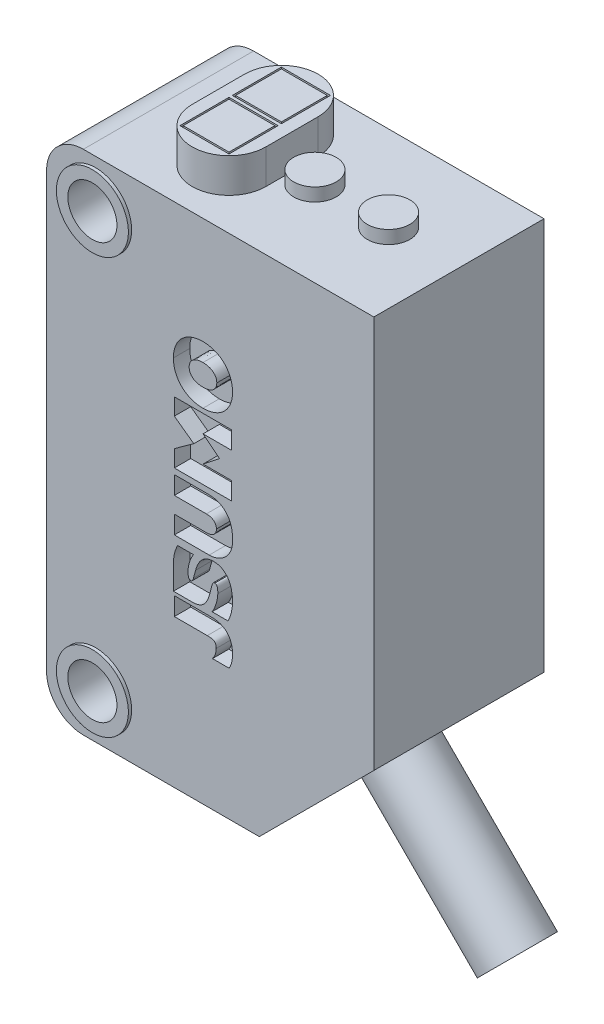
from build123d import *

# Parameters (mm, degrees)
SALIENTE_EXTRUIR1_DEPTH           = 10.4
SALIENTE_EXTRUIR2_DEPTH           = 2.1
CROQUIS3_W                        = 3
CROQUIS3_H                        = 3
CORTAR_EXTRUIR1_DEPTH             = 1
CROQUIS4_W                        = 2.8
CROQUIS4_H                        = 2.8
SALIENTE_EXTRUIR3_DEPTH           = 1
CROQUIS5_W                        = 3
CROQUIS5_H                        = 3
CORTAR_EXTRUIR2_DEPTH             = 1
CROQUIS6_W                        = 2.8
CROQUIS6_H                        = 2.8
SALIENTE_EXTRUIR4_DEPTH           = 1
CORTAR_EXTRUIR3_START             = 3
CORTAR_EXTRUIR3_DEPTH             = 1
SALIENTE_EXTRUIR5_START           = 2.999999
SALIENTE_EXTRUIR5_DEPTH           = 1
CROQUIS9_W                        = 7.2
CROQUIS9_H                        = 15.4
CORTAR_EXTRUIR4_DEPTH             = 1
CROQUIS10_W                       = 7
CROQUIS10_H                       = 15.2
SALIENTE_EXTRUIR6_DEPTH           = 1
CORTAR_EXTRUIR5_START             = 3
CORTAR_EXTRUIR5_DEPTH             = 1
CORTAR_EXTRUIR6_DEPTH             = 1
CORTAR_EXTRUIR7_START             = 3
CORTAR_EXTRUIR7_DEPTH             = 1
CORTAR_EXTRUIR8_START             = 3
CORTAR_EXTRUIR8_DEPTH             = 1
CROQUIS15_W                       = 2.2
CROQUIS15_H                       = 0.2
CROQUIS16_W                       = 2.2
CROQUIS16_H                       = 0.2
CROQUIS17_W                       = 1.3
CROQUIS17_H                       = 0.8
CROQUIS18_W                       = 1.3
CROQUIS18_H                       = 0.8
CROQUIS20_W                       = 2.2
CROQUIS20_H                       = 0.2
CROQUIS21_W                       = 2.2
CROQUIS21_H                       = 0.2
DI_METRO_DE_TALADRO_3_0_3_1_D     = 3
DI_METRO_DE_TALADRO_3_0_3_1_DEPTH = 10.8
CHAFL_N1_SIZE2                    = 0.018573
CHAFL_N1_SIZE                     = 0.018603
REDONDEO4_R                       = 1.427409
REDONDEO5_R                       = 2.25


with BuildPart() as part:
    # Croquis1 → Saliente-Extruir1 (new body)
    with BuildSketch(Plane.XY.offset(5.2)):
        Polygon((17, 28.2), (-3, 28.2), (-3, -2.8), (10, -2.8), (17, 4.2), align=None)
    extrude(amount=-SALIENTE_EXTRUIR1_DEPTH)

    # Croquis2 → Saliente-Extruir2 (add)
    with BuildSketch(Plane(origin=(0, 28.2, 0), x_dir=(-1, 0, 0), z_dir=(0, 1, 0))):
        with BuildLine():
            Line((-6.8, -1.6), (-6.8, 1.6))
            ThreePointArc((-6.8, 1.6), (-4.55, 3.85), (-2.3, 1.6))
            Line((-2.3, 1.6), (-2.3, -1.6))
            ThreePointArc((-2.3, -1.6), (-4.55, -3.85), (-6.8, -1.6))
        make_face()
    extrude(amount=SALIENTE_EXTRUIR2_DEPTH)

    # Croquis3 → Cortar-Extruir1 (cut)
    with BuildSketch(Plane(origin=(0, 30.3, 0), x_dir=(-1, 0, 0), z_dir=(0, 1, 0))):
        with Locations((-4.55, 1.6)):
            Rectangle(CROQUIS3_W, CROQUIS3_H)
    extrude(amount=-CORTAR_EXTRUIR1_DEPTH, mode=Mode.SUBTRACT)

    # Croquis4 → Saliente-Extruir3 (add)
    with BuildSketch(Plane(origin=(0, 29.3, 0), x_dir=(-1, 0, 0), z_dir=(0, 1, 0))):
        with Locations((-4.55, 1.6)):
            Rectangle(CROQUIS4_W, CROQUIS4_H)
    extrude(amount=SALIENTE_EXTRUIR3_DEPTH)

    # Croquis5 → Cortar-Extruir2 (cut)
    with BuildSketch(Plane(origin=(0, 30.3, 0), x_dir=(-1, 0, 0), z_dir=(0, 1, 0))):
        with Locations((-4.55, -1.6)):
            Rectangle(CROQUIS5_W, CROQUIS5_H)
    extrude(amount=-CORTAR_EXTRUIR2_DEPTH, mode=Mode.SUBTRACT)

    # Croquis6 → Saliente-Extruir4 (add)
    with BuildSketch(Plane(origin=(0, 29.3, 0), x_dir=(-1, 0, 0), z_dir=(0, 1, 0))):
        with Locations((-4.55, -1.6)):
            Rectangle(CROQUIS6_W, CROQUIS6_H)
    extrude(amount=SALIENTE_EXTRUIR4_DEPTH)

    # Croquis7 → Cortar-Extruir3 (cut)
    with BuildSketch(Plane.XY.offset(2.2).offset(CORTAR_EXTRUIR3_START)):
        with BuildLine():
            add(Edge.make_bspline(
                [(6.556872, 18.148819), (6.483725, 18.150816), (6.337677, 18.154804), (6.121183, 18.188602), (5.910126, 18.244942), (5.707723, 18.327105), (5.516427, 18.432012), (5.340199, 18.560774), (5.182694, 18.711531), (5.047783, 18.882324), (4.937629, 19.069758), (4.851912, 19.269257), (4.792935, 19.478347), (4.758251, 19.693079), (4.754314, 19.837794), (4.75234, 19.910386)],
                knots=[0, 0, 0, 0, 0.077583, 0.154906, 0.231879, 0.30891, 0.386121, 0.462825, 0.539834, 0.616769, 0.693013, 0.769892, 0.846517, 0.923009, 1, 1, 1, 1], degree=3))
            add(Edge.make_bspline(
                [(4.75234, 19.910386), (4.755244, 19.996969), (4.761039, 20.169708), (4.810891, 20.424588), (4.896052, 20.669184), (5.016774, 20.897814), (5.171979, 21.104833), (5.358358, 21.283013), (5.57019, 21.430011), (5.801571, 21.543646), (6.046304, 21.623739), (6.300022, 21.670701), (6.471081, 21.675937), (6.556872, 21.678564)],
                knots=[0, 0, 0, 0, 0.091665, 0.182879, 0.273878, 0.36517, 0.455665, 0.546797, 0.637127, 0.72777, 0.8189, 0.909173, 1, 1, 1, 1], degree=3))
            add(Edge.make_bspline(
                [(6.556872, 21.678564), (6.630149, 21.676559), (6.776466, 21.672556), (6.993384, 21.638707), (7.204923, 21.582404), (7.40789, 21.500435), (7.599335, 21.395146), (7.775018, 21.265316), (7.930975, 21.1125), (8.065046, 20.940354), (8.175389, 20.75225), (8.262615, 20.552773), (8.322906, 20.343496), (8.35857, 20.128313), (8.362659, 19.983181), (8.36471, 19.910386)],
                knots=[0, 0, 0, 0, 0.077553, 0.154856, 0.23183, 0.308876, 0.386038, 0.462576, 0.539436, 0.616515, 0.692911, 0.769779, 0.846411, 0.922962, 1, 1, 1, 1], degree=3))
            add(Edge.make_bspline(
                [(8.36471, 19.910386), (8.36257, 19.837209), (8.358298, 19.691134), (8.322, 19.47499), (8.261259, 19.265189), (8.172668, 19.065609), (8.061324, 18.878222), (7.926162, 18.707184), (7.769055, 18.556054), (7.592739, 18.427714), (7.400911, 18.323567), (7.198592, 18.243), (6.988502, 18.1873), (6.773795, 18.154423), (6.62935, 18.150691), (6.556872, 18.148819)],
                knots=[0, 0, 0, 0, 0.077586, 0.154877, 0.231765, 0.308711, 0.38586, 0.462416, 0.539246, 0.616397, 0.693033, 0.77021, 0.846843, 0.92315, 1, 1, 1, 1], degree=3))
        make_face()
    extrude(amount=-CORTAR_EXTRUIR3_DEPTH, mode=Mode.SUBTRACT)

    # Croquis8 → Saliente-Extruir5 (add)
    with BuildSketch(Plane.YX.offset(-7.199999).offset(SALIENTE_EXTRUIR5_START)):
        with BuildLine():
            add(Edge.make_bspline(
                [(19.910386, 7.402953), (19.955401, 7.400482), (20.045168, 7.395552), (20.174236, 7.352347), (20.288533, 7.280318), (20.383659, 7.184737), (20.458699, 7.073121), (20.512232, 6.950162), (20.546386, 6.821354), (20.565151, 6.689688), (20.567102, 6.601264), (20.568082, 6.556872)],
                knots=[0, 0, 0, 0, 0.112118, 0.223579, 0.335249, 0.446416, 0.557621, 0.668998, 0.779436, 0.889269, 1, 1, 1, 1], degree=3))
            add(Edge.make_bspline(
                [(20.568082, 6.556872), (20.567108, 6.512451), (20.565165, 6.42381), (20.546234, 6.291805), (20.511925, 6.162817), (20.457847, 6.039851), (20.382001, 5.92867), (20.286302, 5.834214), (20.172344, 5.763528), (20.044249, 5.721475), (19.955146, 5.716563), (19.910386, 5.714096)],
                knots=[0, 0, 0, 0, 0.111022, 0.221544, 0.332555, 0.443846, 0.555736, 0.667127, 0.777586, 0.888274, 1, 1, 1, 1], degree=3))
            add(Edge.make_bspline(
                [(19.910386, 5.714096), (19.865782, 5.716498), (19.776895, 5.721285), (19.649022, 5.763678), (19.535856, 5.835057), (19.442112, 5.930472), (19.368765, 6.041985), (19.316647, 6.164709), (19.283618, 6.293206), (19.265415, 6.424535), (19.263543, 6.512687), (19.262605, 6.556872)],
                knots=[0, 0, 0, 0, 0.111874, 0.222944, 0.334151, 0.445119, 0.556478, 0.667657, 0.778571, 0.889013, 1, 1, 1, 1], degree=3))
            add(Edge.make_bspline(
                [(19.262605, 6.556872), (19.263548, 6.60115), (19.265429, 6.689488), (19.283687, 6.821098), (19.31677, 6.949936), (19.36898, 7.073198), (19.442548, 7.18545), (19.536363, 7.281307), (19.649272, 7.353128), (19.776902, 7.395546), (19.865747, 7.400476), (19.910386, 7.402953)],
                knots=[0, 0, 0, 0, 0.111002, 0.221461, 0.332406, 0.443751, 0.555604, 0.667102, 0.777567, 0.88824, 1, 1, 1, 1], degree=3))
        make_face()
    extrude(amount=-SALIENTE_EXTRUIR5_DEPTH)

    # Croquis9 → Cortar-Extruir4 (cut)
    with BuildSketch(Plane.ZY.offset(3)):
        with Locations((0, 12.7)):
            Rectangle(CROQUIS9_W, CROQUIS9_H)
    extrude(amount=-CORTAR_EXTRUIR4_DEPTH, mode=Mode.SUBTRACT)

    # Croquis10 → Saliente-Extruir6 (add)
    with BuildSketch(Plane.ZY.offset(2)):
        with Locations((0, 12.7)):
            Rectangle(CROQUIS10_W, CROQUIS10_H)
    extrude(amount=SALIENTE_EXTRUIR6_DEPTH)

    # Croquis11 → Cortar-Extruir5 (cut)
    with BuildSketch(Plane.XY.offset(2.2).offset(CORTAR_EXTRUIR5_START)):
        with BuildLine():
            Line((7.112113, 9.066666), (6.973303, 8.531255))
            add(Edge.make_bspline(
                [(6.973303, 8.531255), (6.955912, 8.468461), (6.921217, 8.343179), (6.849591, 8.161506), (6.758362, 7.988744), (6.639771, 7.832516), (6.489756, 7.705008), (6.31243, 7.620371), (6.122535, 7.573299), (5.927389, 7.561443), (5.732121, 7.563278), (5.536184, 7.562784), (5.340227, 7.562917), (5.144263, 7.562881), (4.948302, 7.56289), (4.81766, 7.562889), (4.75234, 7.562889)],
                knots=[0, 0, 0, 0, 0.071468, 0.142587, 0.213863, 0.285264, 0.356574, 0.427679, 0.498905, 0.569946, 0.641582, 0.713266, 0.784949, 0.856633, 0.928316, 1, 1, 1, 1], degree=3))
            add(Edge.make_bspline(
                [(4.75234, 7.562889), (4.75234, 7.641286), (4.752341, 7.798081), (4.752335, 8.033273), (4.752357, 8.268465), (4.752274, 8.503656), (4.752583, 8.738847), (4.751432, 8.973949), (4.756671, 9.208977), (4.780691, 9.443058), (4.832941, 9.672404), (4.905302, 9.89614), (4.968578, 10.039413), (5.000215, 10.111047)],
                knots=[0, 0, 0, 0, 0.090975, 0.18195, 0.272925, 0.363901, 0.454876, 0.545848, 0.636727, 0.727592, 0.818347, 0.909177, 1, 1, 1, 1], degree=3))
            Line((5.000215, 10.111047), (5.981801, 10.111047))
            add(Edge.make_bspline(
                [(5.981801, 10.111047), (5.941398, 10.04575), (5.8607, 9.915332), (5.766082, 9.704853), (5.695092, 9.485476), (5.652387, 9.25786), (5.647258, 9.104001), (5.644691, 9.027006)],
                knots=[0, 0, 0, 0, 0.199872, 0.399203, 0.599389, 0.799522, 1, 1, 1, 1], degree=3))
            add(Edge.make_bspline(
                [(5.644691, 9.027006), (5.644922, 9.006078), (5.645382, 8.964288), (5.650072, 8.901753), (5.659105, 8.839635), (5.673072, 8.778216), (5.693918, 8.71901), (5.736722, 8.66771), (5.778939, 8.660464), (5.800026, 8.656845)],
                knots=[0, 0, 0, 0, 0.1431, 0.285746, 0.42843, 0.572117, 0.715442, 0.857868, 1, 1, 1, 1], degree=3))
            add(Edge.make_bspline(
                [(5.800026, 8.656845), (5.806361, 8.656986), (5.81904, 8.657267), (5.837897, 8.65988), (5.85637, 8.664565), (5.873994, 8.671884), (5.89023, 8.681989), (5.904379, 8.694883), (5.915865, 8.710179), (5.925724, 8.726548), (5.934547, 8.743537), (5.942418, 8.760978), (5.949553, 8.77872), (5.955996, 8.796723), (5.961822, 8.814943), (5.967137, 8.833318), (5.970304, 8.845668), (5.971886, 8.85184)],
                knots=[0, 0, 0, 0, 0.066408, 0.132903, 0.199147, 0.26576, 0.332201, 0.398718, 0.465217, 0.532037, 0.598964, 0.665842, 0.732619, 0.799443, 0.86631, 0.933183, 1, 1, 1, 1], degree=3))
            Line((5.971886, 8.85184), (6.107391, 9.350896))
            add(Edge.make_bspline(
                [(6.107391, 9.350896), (6.124781, 9.408738), (6.159482, 9.524165), (6.22699, 9.692179), (6.309121, 9.853763), (6.410653, 10.004641), (6.535163, 10.137524), (6.682919, 10.244074), (6.848726, 10.318819), (7.026188, 10.361732), (7.147252, 10.366465), (7.207958, 10.368838)],
                knots=[0, 0, 0, 0, 0.111151, 0.221808, 0.332849, 0.444308, 0.55549, 0.666318, 0.777362, 0.888361, 1, 1, 1, 1], degree=3))
            add(Edge.make_bspline(
                [(7.207958, 10.368838), (7.274288, 10.366206), (7.406355, 10.360965), (7.599778, 10.313101), (7.777624, 10.225287), (7.934842, 10.104911), (8.066753, 9.956784), (8.170503, 9.787886), (8.248583, 9.605628), (8.303439, 9.415687), (8.339029, 9.221838), (8.360916, 9.025914), (8.363443, 8.894548), (8.36471, 8.828705)],
                knots=[0, 0, 0, 0, 0.091618, 0.182415, 0.273062, 0.363956, 0.454492, 0.545705, 0.636789, 0.727809, 0.818436, 0.908997, 1, 1, 1, 1], degree=3))
            ThreePointArc((8.36471, 8.828705), (8.297363, 8.227351), (8.090394, 7.658734))
            Line((8.090394, 7.658734), (7.115418, 7.658734))
            add(Edge.make_bspline(
                [(7.115418, 7.658734), (7.155834, 7.727806), (7.236564, 7.865778), (7.326556, 8.08885), (7.39839, 8.317637), (7.453603, 8.552301), (7.461702, 8.712368), (7.465748, 8.79235)],
                knots=[0, 0, 0, 0, 0.199963, 0.399423, 0.599832, 0.800046, 1, 1, 1, 1], degree=3))
            add(Edge.make_bspline(
                [(7.465748, 8.79235), (7.465653, 8.812737), (7.465463, 8.853483), (7.463241, 8.914528), (7.458786, 8.975387), (7.451175, 9.035991), (7.440338, 9.096173), (7.423174, 9.155299), (7.392435, 9.208755), (7.342807, 9.249605), (7.30142, 9.253232), (7.280668, 9.255051)],
                knots=[0, 0, 0, 0, 0.111213, 0.22228, 0.333176, 0.444018, 0.555293, 0.666762, 0.777925, 0.888647, 1, 1, 1, 1], degree=3))
            add(Edge.make_bspline(
                [(7.280668, 9.255051), (7.275526, 9.254964), (7.265242, 9.25479), (7.249883, 9.253213), (7.234728, 9.250399), (7.21992, 9.246034), (7.205756, 9.239846), (7.192571, 9.231721), (7.180945, 9.22148), (7.171141, 9.209483), (7.16309, 9.196249), (7.155584, 9.182686), (7.148759, 9.168744), (7.142447, 9.154573), (7.136555, 9.140229), (7.131047, 9.125735), (7.125881, 9.111109), (7.121027, 9.096375), (7.116428, 9.081561), (7.113551, 9.07163), (7.112113, 9.066666)],
                knots=[0, 0, 0, 0, 0.055408, 0.110811, 0.166162, 0.221319, 0.27682, 0.332262, 0.387543, 0.442988, 0.498534, 0.554262, 0.610031, 0.665753, 0.721428, 0.777124, 0.832843, 0.888576, 0.944304, 1, 1, 1, 1], degree=3))
        make_face()
    extrude(amount=-CORTAR_EXTRUIR5_DEPTH, mode=Mode.SUBTRACT)

    # Croquis12 → Cortar-Extruir6 (cut)
    with BuildSketch(Plane.XY.offset(5.2)):
        Polygon((8.308525, 15.197449), (6.563482, 15.197449), (7.569534, 15.995584), (6.563482, 16.797072), (8.308525, 16.797072), (8.308525, 17.881113), (4.808525, 17.881113), (4.808525, 16.856562), (5.998326, 15.993955), (4.808525, 15.137959), (4.808525, 14.113408), (8.308525, 14.113408), align=None)
    extrude(amount=-CORTAR_EXTRUIR6_DEPTH, mode=Mode.SUBTRACT)

    # Croquis13 → Cortar-Extruir7 (cut)
    with BuildSketch(Plane.XY.offset(2.2).offset(CORTAR_EXTRUIR7_START)):
        with BuildLine():
            Line((4.808525, 10.570443), (4.808525, 11.671009))
            Line((4.808525, 11.671009), (6.765087, 11.671009))
            add(Edge.make_bspline(
                [(6.765087, 11.671009), (6.798075, 11.671722), (6.86394, 11.673144), (6.962096, 11.687251), (7.057913, 11.71315), (7.148724, 11.754261), (7.229683, 11.812429), (7.296983, 11.885709), (7.34624, 11.971953), (7.374902, 12.067539), (7.378175, 12.133586), (7.379818, 12.16676)],
                knots=[0, 0, 0, 0, 0.111168, 0.221966, 0.333409, 0.44482, 0.556141, 0.66724, 0.777653, 0.888318, 1, 1, 1, 1], degree=3))
            add(Edge.make_bspline(
                [(7.379818, 12.16676), (7.378245, 12.200104), (7.375109, 12.266601), (7.346526, 12.363133), (7.296983, 12.450242), (7.22886, 12.523627), (7.147217, 12.581105), (7.05633, 12.621371), (6.960932, 12.64667), (6.863419, 12.660407), (6.797952, 12.661808), (6.765087, 12.662511)],
                knots=[0, 0, 0, 0, 0.11211, 0.223573, 0.335329, 0.446725, 0.557966, 0.669267, 0.779636, 0.889376, 1, 1, 1, 1], degree=3))
            Line((6.765087, 12.662511), (4.808525, 12.662511))
            Line((4.808525, 12.662511), (4.808525, 13.763077))
            Line((4.808525, 13.763077), (6.860933, 13.763077))
            add(Edge.make_bspline(
                [(6.860933, 13.763077), (6.946499, 13.760392), (7.117333, 13.75503), (7.369671, 13.704425), (7.609615, 13.613721), (7.828594, 13.479669), (8.013554, 13.302001), (8.159388, 13.091279), (8.262832, 12.857296), (8.328761, 12.611535), (8.362783, 12.35939), (8.365231, 12.104873), (8.36457, 11.849507), (8.364747, 11.593679), (8.3647, 11.337874), (8.364712, 11.082063), (8.364709, 10.826253), (8.364709, 10.655713), (8.36471, 10.570443)],
                knots=[0, 0, 0, 0, 0.062833, 0.125447, 0.188128, 0.250468, 0.312777, 0.375206, 0.437599, 0.499828, 0.561636, 0.624021, 0.686685, 0.749348, 0.812011, 0.874674, 0.937337, 1, 1, 1, 1], degree=3))
            Line((8.36471, 10.570443), (4.808525, 10.570443))
        make_face()
    extrude(amount=-CORTAR_EXTRUIR7_DEPTH, mode=Mode.SUBTRACT)

    # Croquis14 → Cortar-Extruir8 (cut)
    with BuildSketch(Plane.XY.offset(2.2).offset(CORTAR_EXTRUIR8_START)):
        with BuildLine():
            Line((6.821272, 6.250802), (4.808525, 6.250802))
            Line((4.808525, 6.250802), (4.808525, 7.357978))
            Line((4.808525, 7.357978), (7.065843, 7.357978))
            add(Edge.make_bspline(
                [(7.065843, 7.357978), (7.144479, 7.355834), (7.301391, 7.351555), (7.533638, 7.307448), (7.754343, 7.2241), (7.954559, 7.098474), (8.119905, 6.929049), (8.240554, 6.725641), (8.315854, 6.503084), (8.357883, 6.272586), (8.36243, 6.117203), (8.36471, 6.039281)],
                knots=[0, 0, 0, 0, 0.11179, 0.223069, 0.334514, 0.445622, 0.556592, 0.668011, 0.779099, 0.889223, 1, 1, 1, 1], degree=3))
            add(Edge.make_bspline(
                [(8.36471, 6.039281), (8.364047, 5.996962), (8.362722, 5.912377), (8.351202, 5.786009), (8.33165, 5.660808), (8.302689, 5.537366), (8.264321, 5.416791), (8.21988, 5.297729), (8.175422, 5.225843), (8.153189, 5.189895)],
                knots=[0, 0, 0, 0, 0.143186, 0.28619, 0.428976, 0.571731, 0.714658, 0.85731, 1, 1, 1, 1], degree=3))
            Line((8.153189, 5.189895), (7.138553, 5.189895))
            add(Edge.make_bspline(
                [(7.138553, 5.189895), (7.164815, 5.229057), (7.21723, 5.307219), (7.282512, 5.4323), (7.332911, 5.563982), (7.361592, 5.702768), (7.364926, 5.797018), (7.366598, 5.844286)],
                knots=[0, 0, 0, 0, 0.200574, 0.400315, 0.599104, 0.798946, 1, 1, 1, 1], degree=3))
            add(Edge.make_bspline(
                [(7.366598, 5.844286), (7.366136, 5.868541), (7.365215, 5.916933), (7.354819, 5.98882), (7.334171, 6.058312), (7.299257, 6.122504), (7.244729, 6.171931), (7.178994, 6.203226), (7.109513, 6.224375), (7.03808, 6.237436), (6.966033, 6.245742), (6.893704, 6.250149), (6.845427, 6.250584), (6.821272, 6.250802)],
                knots=[0, 0, 0, 0, 0.091366, 0.182285, 0.272778, 0.363531, 0.453948, 0.544845, 0.635776, 0.727081, 0.818083, 0.908979, 1, 1, 1, 1], degree=3))
        make_face()
    extrude(amount=-CORTAR_EXTRUIR8_DEPTH, mode=Mode.SUBTRACT)

    # Croquis15 → Revolución1 (revolve)
    with BuildSketch(Plane(origin=(0, 25.4, 0), x_dir=(1, 0, 0), z_dir=(0, 1, 0))):
        with Locations((1.1, 5.3)):
            Rectangle(CROQUIS15_W, CROQUIS15_H)
    revolve(axis=Axis((0, 25.4, -5.4), (0, 0, 1)))

    # Croquis16 → Revolución2 (revolve)
    with BuildSketch(Plane(origin=(0, 0, 0), x_dir=(1, 0, 0), z_dir=(0, 1, 0))):
        with Locations((1.1, 5.3)):
            Rectangle(CROQUIS16_W, CROQUIS16_H)
    revolve(axis=Axis((0, 0, -5.4), (0, 0, 1)))

    # Croquis17 → Revolución3 (revolve)
    with BuildSketch(Plane.XY):
        with Locations((8.85, 28.6)):
            Rectangle(CROQUIS17_W, CROQUIS17_H)
    revolve(axis=Axis((8.2, 29, 0), (0, -1, 0)))

    # Croquis18 → Revolución4 (revolve)
    with BuildSketch(Plane.XY):
        with Locations((13.35, 28.6)):
            Rectangle(CROQUIS18_W, CROQUIS18_H)
    revolve(axis=Axis((12.7, 29, 0), (0, -1, 0)))

    # Croquis19 → Revolución5 (revolve)
    with BuildSketch(Plane.XY):
        Polygon((13.5, 0.7), (12.085786, -0.714214), (19.156854, -7.785281), (20.571068, -6.371068), align=None)
    revolve(axis=Axis((20.571068, -6.371068, 0), (-0.707107, 0.707107, 0)))

    # Croquis20 → Revolución6 (revolve)
    with BuildSketch(Plane.XZ):
        with Locations((1.1, 5.3)):
            Rectangle(CROQUIS20_W, CROQUIS20_H)
    revolve(axis=Axis((0, 0, 5.4), (0, 0, -1)))

    # Croquis21 → Revolución7 (revolve)
    with BuildSketch(Plane.XZ.offset(-25.4)):
        with Locations((1.1, 5.3)):
            Rectangle(CROQUIS21_W, CROQUIS21_H)
    revolve(axis=Axis((0, 25.4, 5.4), (0, 0, -1)))

    # Diámetro de taladro Ø3.0 (3)1
    with Locations(Plane.XY.offset(5.4)):
        with Locations((0, 0), (0, 25.4)):
            Hole(DI_METRO_DE_TALADRO_3_0_3_1_D / 2, depth=DI_METRO_DE_TALADRO_3_0_3_1_DEPTH)

    # Chaflán1
    chafl_n1_edges = [part.edges().sort_by_distance(p)[0] for p in [
        (7.569534, 15.995584, 4.7),
    ]]
    chamfer(chafl_n1_edges, length=CHAFL_N1_SIZE, length2=CHAFL_N1_SIZE2)

    # Redondeo4
    redondeo4_edges = [part.edges().sort_by_distance(p)[0] for p in [
        (8.36471, 10.570443, 4.7),
    ]]
    fillet(redondeo4_edges, radius=REDONDEO4_R)

    # Redondeo5
    redondeo5_edges = [part.edges().sort_by_distance(p)[0] for p in [
        (-3, -2.8, 0),
        (-3, 28.2, 0),
    ]]
    fillet(redondeo5_edges, radius=REDONDEO5_R)


solid = part.part
